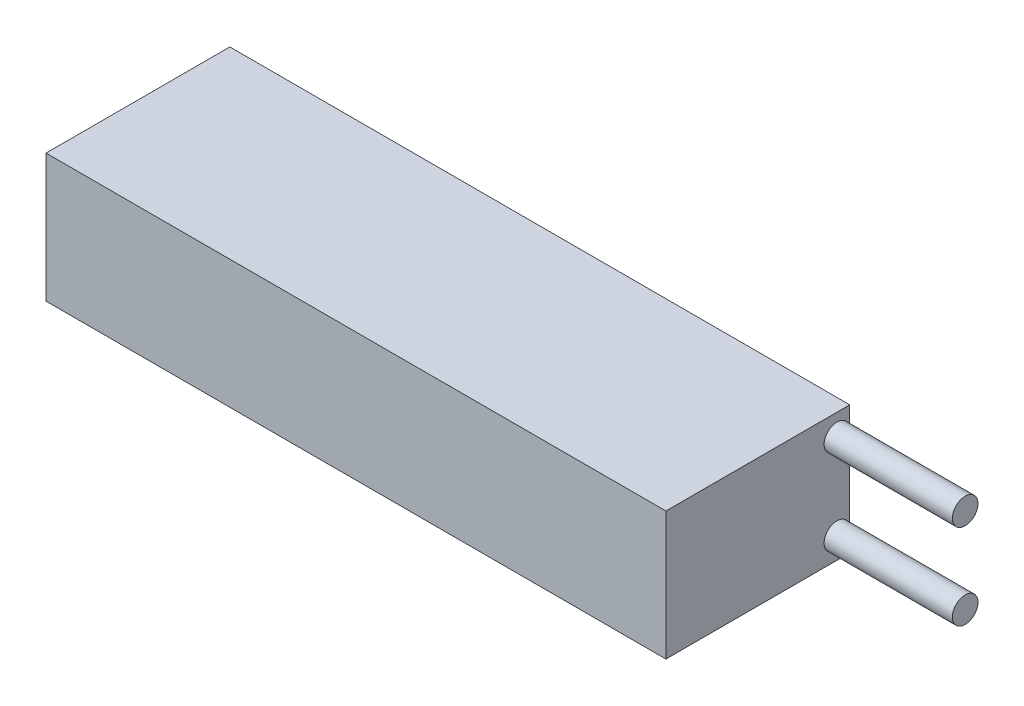
from build123d import *

# Parameters (mm, degrees)
SKETCH1_W           = 145
SKETCH1_H           = 43
BOSS_EXTRUDE1_DEPTH = 30
SKETCH2_R           = 3
BOSS_EXTRUDE2_DEPTH = 30


with BuildPart() as part:
    # Sketch1 → Boss-Extrude1 (new body)
    with BuildSketch(Plane(origin=(0, 0, 0), x_dir=(1, 0, 0), z_dir=(0, 1, 0))):
        Rectangle(SKETCH1_W, SKETCH1_H)
    extrude(amount=BOSS_EXTRUDE1_DEPTH)

    # Sketch2 → Boss-Extrude2 (add)
    with BuildSketch(Plane(origin=(72.5, 0, 0), x_dir=(0, 0, -1), z_dir=(1, 0, 0))):
        with Locations((18.5, 25)):
            Circle(SKETCH2_R)
        with Locations((18.5, 5)):
            Circle(SKETCH2_R)
    extrude(amount=BOSS_EXTRUDE2_DEPTH)


solid = part.part
